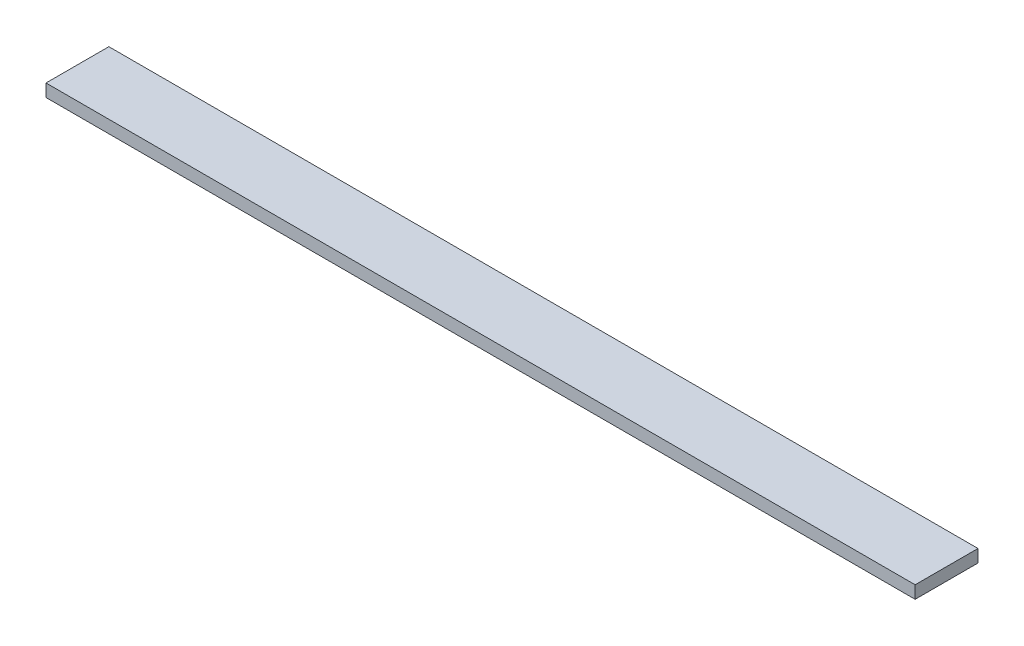
from build123d import *

# Parameters (mm, degrees)
SKETCH1_W      = 341.217
SKETCH1_H      = 24.68
EXTRUDE1_DEPTH = 2.4765


with BuildPart() as part:
    # Sketch1 → Extrude1 (new body, symmetric)
    with BuildSketch(Plane(origin=(0, 0, 0), x_dir=(1, 0, 0), z_dir=(0, 1, 0))):
        with Locations((170.6085, 0)):
            Rectangle(SKETCH1_W, SKETCH1_H)
    extrude(amount=EXTRUDE1_DEPTH, both=True)


solid = part.part
